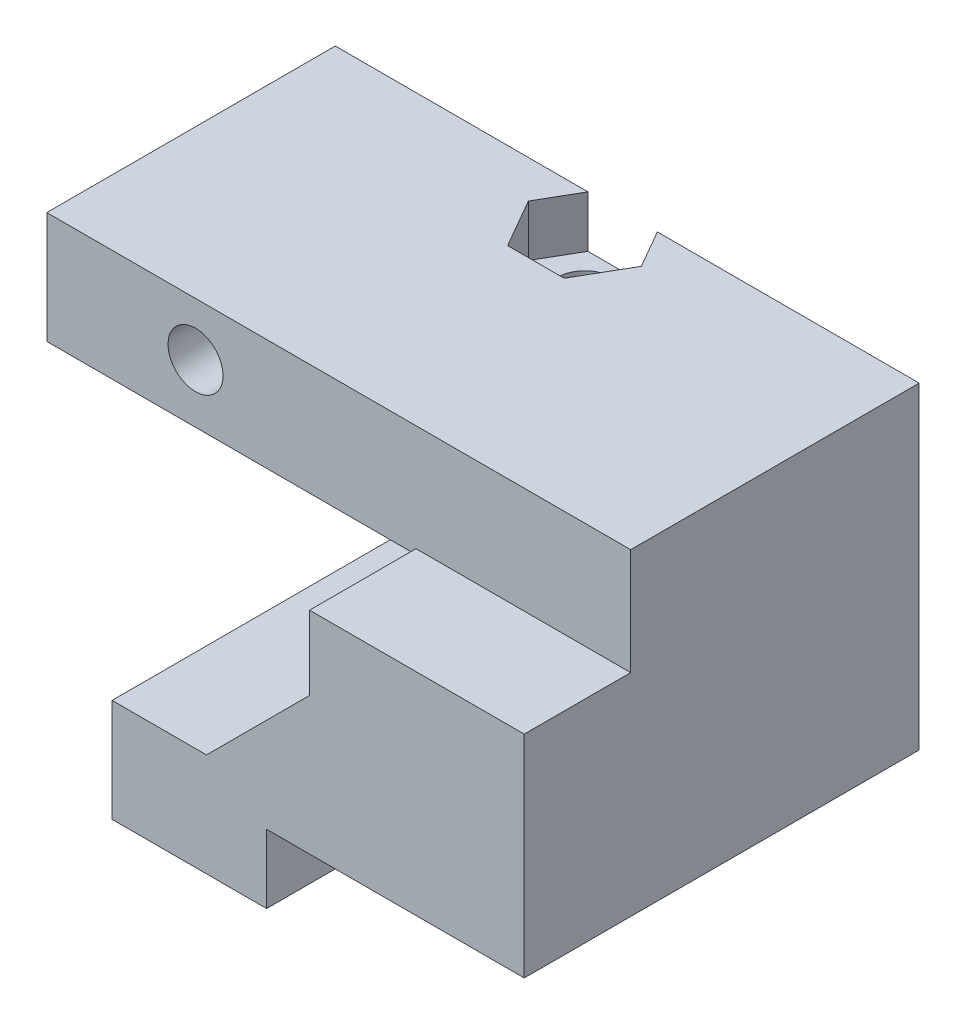
from build123d import *

# Parameters (mm, degrees)
SALIENTE_EXTRUIR1_DEPTH           = 23
CROQUIS2_W                        = 34
CROQUIS2_H                        = 6.2
CORTAR_EXTRUIR1_DEPTH             = 6.2
CROQUIS3_W                        = 21.5
CROQUIS3_H                        = 0.3
CORTAR_EXTRUIR2_DEPTH             = 6.2
CORTAR_EXTRUIR3_REACH             = 18.8
CROQUIS4_R                        = 1.6
CORTAR_EXTRUIR4_DEPTH             = 9.8
CORTAR_EXTRUIR5_REACH             = 8.5
CROQUIS6_R                        = 1.6
CORTAR_EXTRUIR6_REACH             = 24.5
CROQUIS7_R                        = 1.6
SALIENTE_EXTRUIR2_DEPTH           = 23
CORTAR_EXTRUIR7_DEPTH             = 4
CORTAR_EXTRUIR7_DIRECTION_2_REACH = 18.5
CORTAR_EXTRUIR8_DEPTH             = 3


with BuildPart() as part:
    # Croquis1 → Saliente-Extruir1 (new body)
    with BuildSketch(Plane.XY):
        Polygon((0, 0), (9, 0), (9, 4), (24, 4), (24, 22.5), (-10, 22.5), (-10, 16), (11.5, 16), (11.5, 6), (0, 6), align=None)
    extrude(amount=SALIENTE_EXTRUIR1_DEPTH)

    # Croquis2 → Cortar-Extruir1 (cut)
    with BuildSketch(Plane.XY.offset(23)):
        with Locations((7, 19.4)):
            Rectangle(CROQUIS2_W, CROQUIS2_H)
    extrude(amount=-CORTAR_EXTRUIR1_DEPTH, mode=Mode.SUBTRACT)

    # Croquis3 → Cortar-Extruir2 (cut)
    with BuildSketch(Plane.XY.offset(23)):
        with Locations((0.75, 16.15)):
            Rectangle(CROQUIS3_W, CROQUIS3_H)
    extrude(amount=-CORTAR_EXTRUIR2_DEPTH, mode=Mode.SUBTRACT)

    # Croquis4 → Cortar-Extruir3 (cut, up to next)
    with BuildSketch(Plane.XY.offset(16.8), mode=Mode.PRIVATE) as cortar_extruir3_sk1:
        with Locations((-1.34, 19.4)):
            Circle(CROQUIS4_R)
    cortar_extruir3_tool1 = extrude(cortar_extruir3_sk1.sketch, amount=-CORTAR_EXTRUIR3_REACH, mode=Mode.PRIVATE) & part.part
    add(cortar_extruir3_tool1.solids().sort_by_distance((-1.34, 19.4, 16.8))[0], mode=Mode.SUBTRACT)

    # Croquis5 → Cortar-Extruir4 (cut)
    with BuildSketch(Plane(origin=(0, 0, 0), x_dir=(-1, 0, 0), z_dir=(0, 0, -1))):
        Polygon((-1.950896534, 19.4), (-0.305448267, 16.55), (2.985448267, 16.55), (4.630896534, 19.4), (2.985448267, 22.25), (-0.305448267, 22.25), align=None)
    extrude(amount=-CORTAR_EXTRUIR4_DEPTH, mode=Mode.SUBTRACT)

    # Croquis6 → Cortar-Extruir5 (cut, up to next)
    with BuildSketch(Plane.XZ.offset(-16), mode=Mode.PRIVATE) as cortar_extruir5_sk1:
        with Locations((6.73, 2.2)):
            Circle(CROQUIS6_R)
    cortar_extruir5_tool1 = extrude(cortar_extruir5_sk1.sketch, amount=-CORTAR_EXTRUIR5_REACH, mode=Mode.PRIVATE) & part.part
    add(cortar_extruir5_tool1.solids().sort_by_distance((6.73, 16, 2.2))[0], mode=Mode.SUBTRACT)

    # Croquis7 → Cortar-Extruir6 (cut, up to next)
    with BuildSketch(Plane.XZ, mode=Mode.PRIVATE) as cortar_extruir6_sk1:
        with Locations((4.95, 3.3)):
            Circle(CROQUIS7_R)
    cortar_extruir6_tool1 = extrude(cortar_extruir6_sk1.sketch, amount=-CORTAR_EXTRUIR6_REACH, mode=Mode.PRIVATE) & part.part
    add(cortar_extruir6_tool1.solids().sort_by_distance((4.95, 0, 3.3))[0], mode=Mode.SUBTRACT)

    # Croquis10 → Saliente-Extruir2 (add)
    with BuildSketch(Plane(origin=(0, 0, 0), x_dir=(-1, 0, 0), z_dir=(0, 0, -1))):
        Polygon((-11.5, 6), (-5.5, 6), (-11.5, 12), align=None)
    extrude(amount=-SALIENTE_EXTRUIR2_DEPTH)

    # Croquis8 → Cortar-Extruir7 (cut)
    with BuildSketch(Plane(origin=(0, 6, 0), x_dir=(1, 0, 0), z_dir=(0, 1, 0))):
        Polygon((1.659103466, -3.3), (3.304551733, -6.15), (6.595448267, -6.15), (8.240896534, -3.3), (6.595448267, -0.45), (3.304551733, -0.45), align=None)
    extrude(amount=-CORTAR_EXTRUIR7_DEPTH, mode=Mode.SUBTRACT)

    # Croquis8 → Cortar-Extruir7 direction 2 (cut, up to next)
    with BuildSketch(Plane(origin=(0, 6, 0), x_dir=(1, 0, 0), z_dir=(0, 1, 0)), mode=Mode.PRIVATE) as cortar_extruir7_direction_2_sk1:
        Polygon((1.659103466, -3.3), (3.304551733, -6.15), (6.595448267, -6.15), (8.240896534, -3.3), (6.595448267, -0.45), (3.304551733, -0.45), align=None)
    cortar_extruir7_direction_2_tool1 = extrude(cortar_extruir7_direction_2_sk1.sketch, amount=CORTAR_EXTRUIR7_DIRECTION_2_REACH, mode=Mode.PRIVATE) & part.part
    add(cortar_extruir7_direction_2_tool1.solids().sort_by_distance((4.95, 6, 3.3))[0], mode=Mode.SUBTRACT)

    # Croquis9 → Cortar-Extruir8 (cut)
    with BuildSketch(Plane(origin=(0, 22.5, 0), x_dir=(1, 0, 0), z_dir=(0, 1, 0))):
        Polygon((3.439103466, -2.2), (5.084551733, -5.05), (8.375448267, -5.05), (10.020896534, -2.2), (8.375448267, 0.65), (5.084551733, 0.65), align=None)
    extrude(amount=-CORTAR_EXTRUIR8_DEPTH, mode=Mode.SUBTRACT)


solid = part.part
